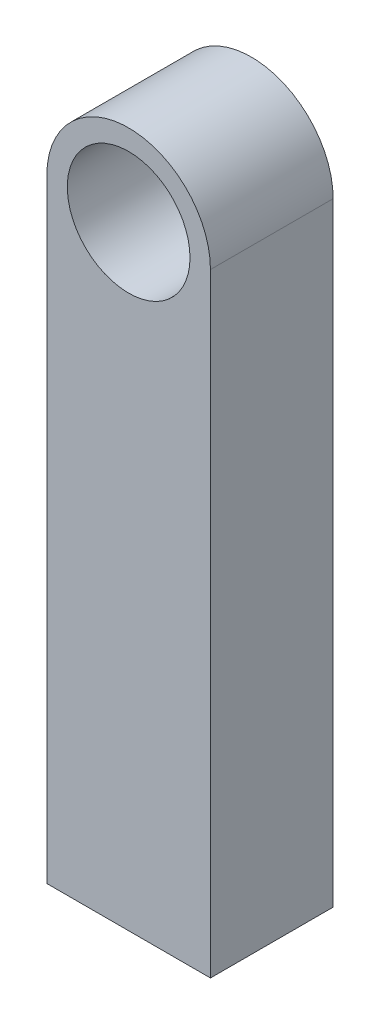
from build123d import *

# Parameters (mm, degrees)
SKETCH_1_R          = 2
SKETCH_1_R_2        = 1.5
EXTRUDE_1_DEPTH     = 3
SKETCH_2_W          = 3
SKETCH_2_H          = 2
CUT_EXTRUDE_1_DEPTH = 10


with BuildPart() as part:
    # 草图1 → 凸台-拉伸1 (new body)
    with BuildSketch(Plane.XY):
        with BuildLine():
            ThreePointArc((2, 0), (0, -2), (-2, 0))
            Line((-2, 0), (-2, -15))
            Line((-2, -15), (2, -15))
            Line((2, -15), (2, 0))
        make_face()
        Circle(SKETCH_1_R)
        Circle(SKETCH_1_R_2, mode=Mode.SUBTRACT)
    extrude(amount=EXTRUDE_1_DEPTH)

    # 草图2 → 切除-拉伸1 (cut)
    with BuildSketch(Plane.XZ.offset(15)):
        with Locations((0, 1.5)):
            Rectangle(SKETCH_2_W, SKETCH_2_H)
    extrude(amount=-CUT_EXTRUDE_1_DEPTH, mode=Mode.SUBTRACT)


solid = part.part
